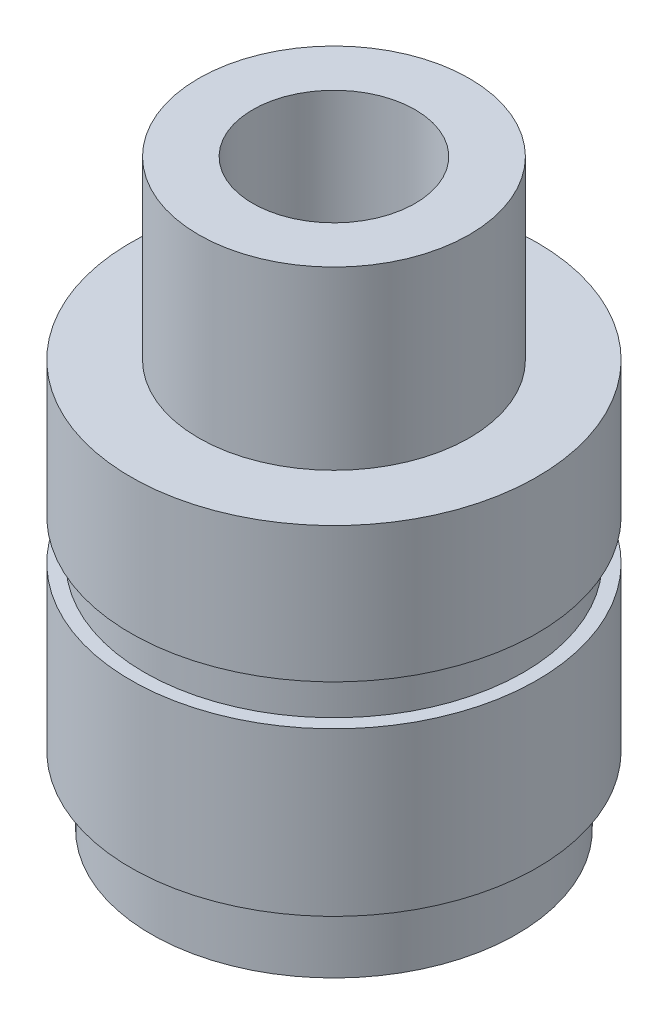
from build123d import *


with BuildPart() as part:
    # 草图1 → 旋转1 (revolve)
    with BuildSketch(Plane.XY):
        Polygon((12, 0), (12, 25), (6, 25), (6, 43), (10, 43), (10, 30), (15, 30), (15, 20), (14, 20), (14, 17), (15, 17), (15, 5), (13.5, 5), (13.5, 0), align=None)
    revolve(axis=Axis((0, 0, 0), (0, 1, 0)))


solid = part.part
